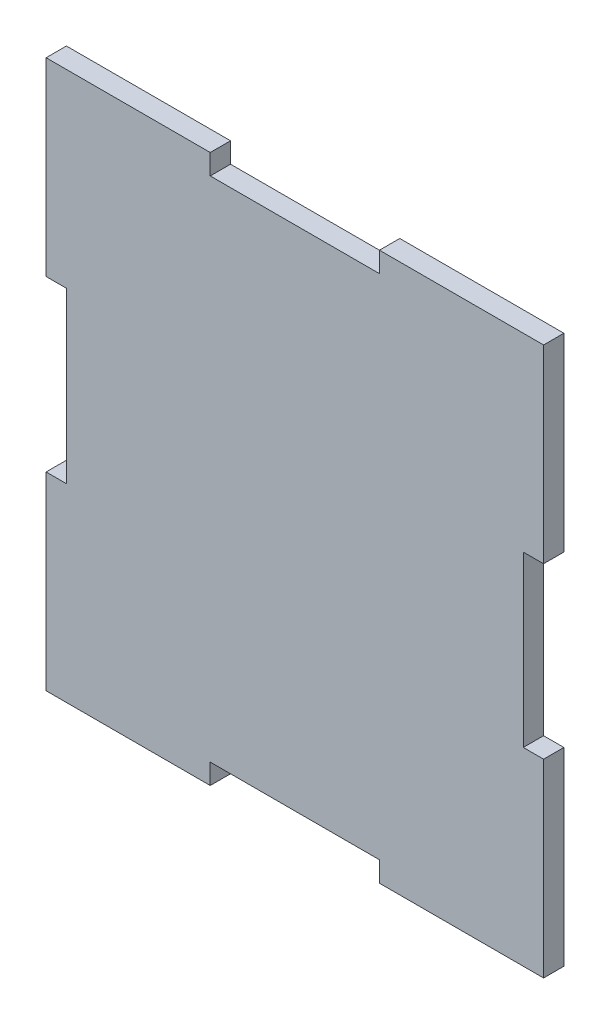
from build123d import *

# Parameters (mm, degrees)
SALIENTE_EXTRUIR1_DEPTH = 6


with BuildPart() as part:
    # Croquis1 → Saliente-Extruir1 (new body)
    with BuildSketch(Plane.XY):
        Polygon((-73.5, 81), (-25, 81), (-25, 75), (25, 75), (25, 81), (73.5, 81), (73.5, 25), (67.5, 25), (67.5, -25), (73.5, -25), (73.5, -81), (25, -81), (25, -75), (-25, -75), (-25, -81), (-73.5, -81), (-73.5, -25), (-67.5, -25), (-67.5, 25), (-73.5, 25), align=None)
    extrude(amount=SALIENTE_EXTRUIR1_DEPTH)


solid = part.part
